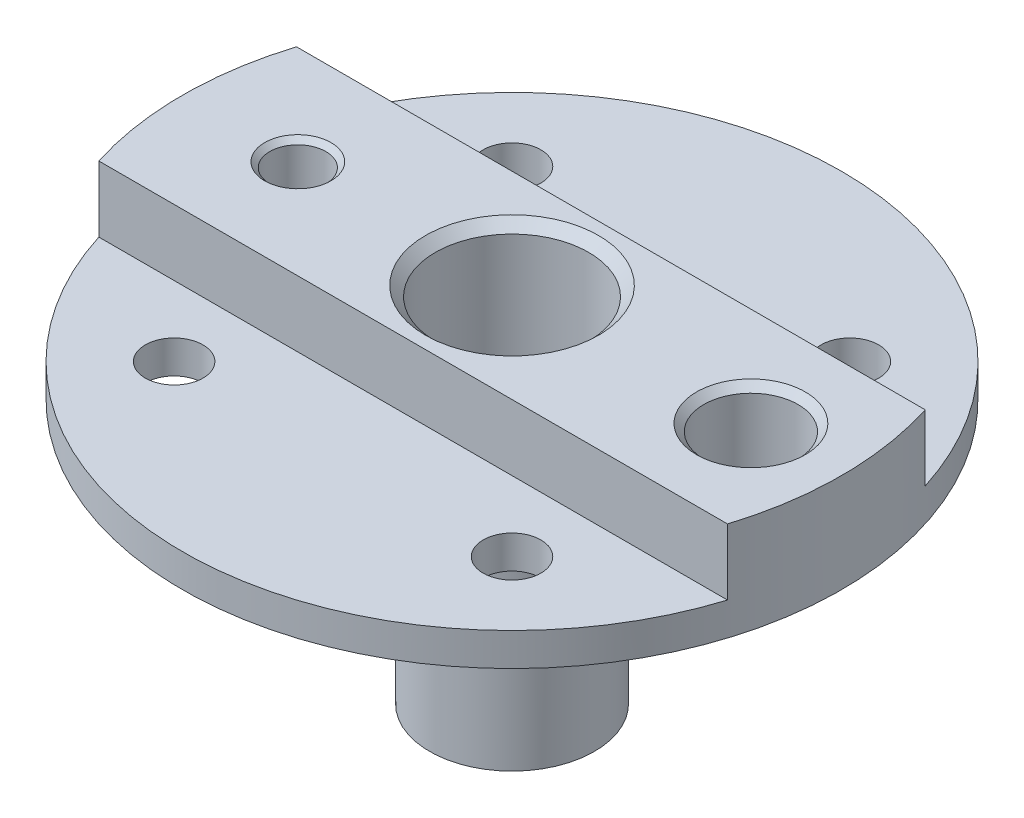
from build123d import *

# Parameters (mm, degrees)
G1_2_TAPPED_HOLE1_D                  = 18.631
G1_2_TAPPED_HOLE1_DEPTH              = 20.44
G1_2_TAPPED_HOLE1_CSINK_D            = 21.005
G1_2_TAPPED_HOLE1_CSINK_ANGLE        = 90
G1_2_TAPPED_HOLE1_TIP                = 5.597317097
CUT_EXTRUDE1_DEPTH                   = 1
CIRPATTERN1_COUNT                    = 8
G1_4_TAPPED_HOLE1_D                  = 11.445
G1_4_TAPPED_HOLE1_CSINK_D            = 13.207
G1_4_TAPPED_HOLE1_CSINK_ANGLE        = 90
M6_CLEARANCE_HOLE1_D                 = 7
M6_CLEARANCE_HOLE1_CSINK_D           = 7.05
M6_CLEARANCE_HOLE1_CSINK_ANGLE       = 90
CIRPATTERN2_COUNT                    = 4
F_2_5_2_5_DIAMETER_HOLE1_D           = 2.5
F_2_5_2_5_DIAMETER_HOLE1_CSINK_D     = 2.55
F_2_5_2_5_DIAMETER_HOLE1_CSINK_ANGLE = 90
CIRPATTERN3_COUNT                    = 8
M8_TAPPED_HOLE2_D                    = 6.8
M8_TAPPED_HOLE2_CSINK_D              = 8.05
M8_TAPPED_HOLE2_CSINK_ANGLE          = 90
M8_TAPPED_HOLE3_D                    = 6.8
M8_TAPPED_HOLE3_DEPTH                = 19.75
M8_TAPPED_HOLE3_CSINK_D              = 8.05
M8_TAPPED_HOLE3_CSINK_ANGLE          = 90
M8_TAPPED_HOLE3_TIP                  = 2.042926105
SKETCH18_W                           = 229.108597894
SKETCH18_H                           = 56.975690792
CUT_EXTRUDE2_DEPTH                   = 8


with BuildPart() as part:
    # Sketch1 → Revolve1 (revolve)
    with BuildSketch(Plane.XY):
        Polygon((-40, 44), (0, 44), (0, 8), (-7.5, 8), (-7.5, 0), (-10, 0), (-10, 13), (-10.1, 13), (-10.1, 17), (-9, 17), (-9, 20), (-12, 20), (-12, 30), (-14, 30), (-14, 32), (-40, 32), align=None)
    revolve(axis=Axis((0, 0, 0), (0, 1, 0)))

    # G1/2 Tapped Hole1
    with Locations(Plane(origin=(0, 44, 0), x_dir=(1, 0, 0), z_dir=(0, 1, 0))):
        with Locations((0, 0)):
            CounterSinkHole(G1_2_TAPPED_HOLE1_D / 2, G1_2_TAPPED_HOLE1_CSINK_D / 2, depth=G1_2_TAPPED_HOLE1_DEPTH, counter_sink_angle=G1_2_TAPPED_HOLE1_CSINK_ANGLE)
            with Locations((0, 0, -(G1_2_TAPPED_HOLE1_DEPTH + G1_2_TAPPED_HOLE1_TIP / 2))):  # 118° drill point
                Cone(0, G1_2_TAPPED_HOLE1_D / 2, G1_2_TAPPED_HOLE1_TIP, mode=Mode.SUBTRACT)

    # Sketch4 → Cut-Extrude1 (cut)
    with BuildSketch(Plane(origin=(10.1, 0, 0), x_dir=(0, 0, -1), z_dir=(1, 0, 0))):
        with BuildLine():
            Line((2, 17), (2, 13))
            ThreePointArc((2, 13), (0, 11), (-2, 13))
            Line((-2, 13), (-2, 17))
            ThreePointArc((-2, 17), (0, 19), (2, 17))
        make_face()
    cut_extrude1 = extrude(amount=-CUT_EXTRUDE1_DEPTH, mode=Mode.SUBTRACT)

    # CirPattern1: Cut-Extrude1 ×8 about axis
    cirpattern1_axis = Axis((0, 0, 0), (0, 1, 0))
    for i in range(1, CIRPATTERN1_COUNT):
        add(cut_extrude1.rotate(cirpattern1_axis, i * 360 / CIRPATTERN1_COUNT), mode=Mode.SUBTRACT)

    # G1/4 Tapped Hole1 (through all)
    with Locations(Plane(origin=(0, 44, 0), x_dir=(1, 0, 0), z_dir=(0, 1, 0))):
        with Locations((29, 0)):
            CounterSinkHole(G1_4_TAPPED_HOLE1_D / 2, G1_4_TAPPED_HOLE1_CSINK_D / 2, counter_sink_angle=G1_4_TAPPED_HOLE1_CSINK_ANGLE)

    # M6 Clearance Hole1 (through all)
    with Locations(Plane(origin=(0, 44, 0), x_dir=(1, 0, 0), z_dir=(0, 1, 0))):
        with Locations((20.506096654, 20.506096654)):
            m6_clearance_hole1 = CounterSinkHole(M6_CLEARANCE_HOLE1_D / 2, M6_CLEARANCE_HOLE1_CSINK_D / 2, counter_sink_angle=M6_CLEARANCE_HOLE1_CSINK_ANGLE)

    # CirPattern2: M6 Clearance Hole1 ×4 about axis
    cirpattern2_axis = Axis((0, 0, 0), (0, 1, 0))
    for i in range(1, CIRPATTERN2_COUNT):
        add(m6_clearance_hole1.rotate(cirpattern2_axis, i * 360 / CIRPATTERN2_COUNT), mode=Mode.SUBTRACT)

    # Ø2.5 (2.5) Diameter Hole1 (through all)
    with Locations(Plane(origin=(0, 8, 0), x_dir=(-1, 0, 0), z_dir=(0, -1, 0))):
        with Locations((6, 0)):
            f_2_5_2_5_diameter_hole1 = CounterSinkHole(F_2_5_2_5_DIAMETER_HOLE1_D / 2, F_2_5_2_5_DIAMETER_HOLE1_CSINK_D / 2, counter_sink_angle=F_2_5_2_5_DIAMETER_HOLE1_CSINK_ANGLE)

    # CirPattern3: Ø2.5 (2.5) Diameter Hole1 ×8 about axis
    cirpattern3_axis = Axis((0, 0, 0), (0, 1, 0))
    for i in range(1, CIRPATTERN3_COUNT):
        add(f_2_5_2_5_diameter_hole1.rotate(cirpattern3_axis, i * 360 / CIRPATTERN3_COUNT), mode=Mode.SUBTRACT)

    # M8 Tapped Hole2 (through all)
    with Locations(Plane(origin=(0, 8, 0), x_dir=(-1, 0, 0), z_dir=(0, -1, 0))):
        with Locations((0, 0)):
            CounterSinkHole(M8_TAPPED_HOLE2_D / 2, M8_TAPPED_HOLE2_CSINK_D / 2, counter_sink_angle=M8_TAPPED_HOLE2_CSINK_ANGLE)

    # M8 Tapped Hole3
    with Locations(Plane(origin=(0, 44, 0), x_dir=(1, 0, 0), z_dir=(0, 1, 0))):
        with Locations((-26, 0)):
            CounterSinkHole(M8_TAPPED_HOLE3_D / 2, M8_TAPPED_HOLE3_CSINK_D / 2, depth=M8_TAPPED_HOLE3_DEPTH, counter_sink_angle=M8_TAPPED_HOLE3_CSINK_ANGLE)
            with Locations((0, 0, -(M8_TAPPED_HOLE3_DEPTH + M8_TAPPED_HOLE3_TIP / 2))):  # 118° drill point
                Cone(0, M8_TAPPED_HOLE3_D / 2, M8_TAPPED_HOLE3_TIP, mode=Mode.SUBTRACT)

    # Sketch18 → Cut-Extrude2 (cut)
    with BuildSketch(Plane(origin=(0, 44, 0), x_dir=(1, 0, 0), z_dir=(0, 1, 0))):
        with Locations((0, 40.487845396)):
            Rectangle(SKETCH18_W, SKETCH18_H)
        with Locations((0, -40.487845396)):
            Rectangle(SKETCH18_W, SKETCH18_H)
    extrude(amount=-CUT_EXTRUDE2_DEPTH, mode=Mode.SUBTRACT)


solid = part.part
